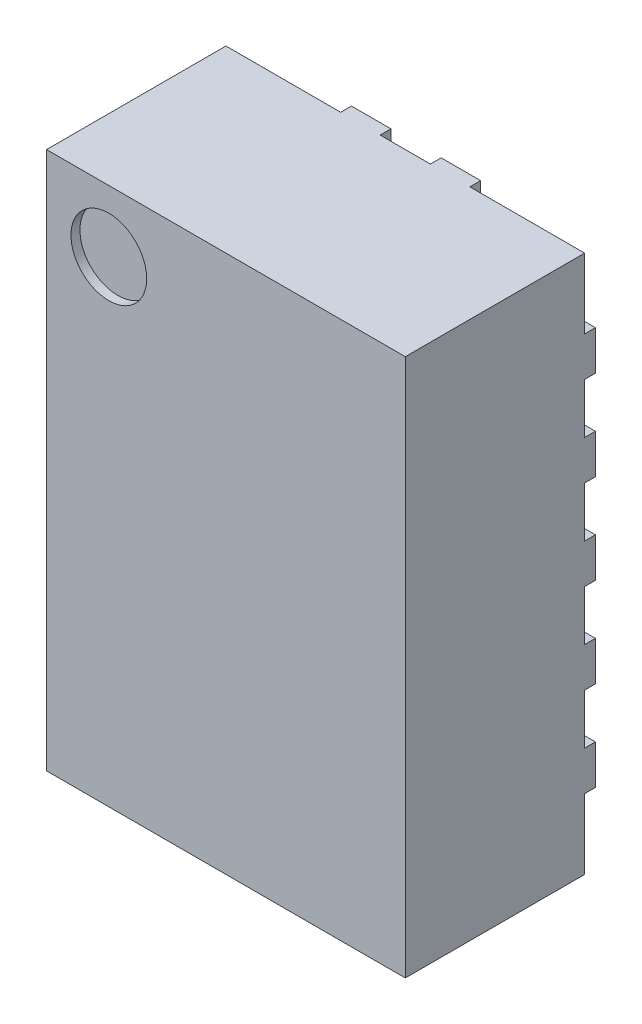
from build123d import *

# Parameters (mm, degrees)
BOSS_EXTRUDE1_START = 0.06
SKETCH1_W           = 2
SKETCH1_H           = 3
BOSS_EXTRUDE1_DEPTH = 1
BOSS_EXTRUDE2_DEPTH = 0.06
CUT_EXTRUDE2_DEPTH  = 0.06
SKETCH2_R           = 0.211135496
CUT_EXTRUDE3_DEPTH  = 0.05


with BuildPart() as part:
    # Sketch1 → Boss-Extrude1 (new body)
    with BuildSketch(Plane.XY.offset(BOSS_EXTRUDE1_START)):
        Rectangle(SKETCH1_W, SKETCH1_H)
    extrude(amount=BOSS_EXTRUDE1_DEPTH)

    # Sketch3 → Boss-Extrude2 (add)
    with BuildSketch(Plane(origin=(0, 0, 0.06), x_dir=(-1, 0, 0), z_dir=(0, 0, -1))):
        with BuildLine():
            Line((1, -0.11), (0.11, -0.11))
            ThreePointArc((0.11, -0.11), (0, 0), (0.11, 0.11))
            Line((0.11, 0.11), (1, 0.11))
            Line((1, 0.11), (1, -0.11))
        make_face()
        with BuildLine():
            Line((1, -0.61), (0.45, -0.61))
            ThreePointArc((0.45, -0.61), (0.34, -0.5), (0.45, -0.39))
            Line((0.45, -0.39), (1, -0.39))
            Line((1, -0.39), (1, -0.61))
        make_face()
        with BuildLine():
            Line((1, -1.11), (0.6, -1.11))
            ThreePointArc((0.6, -1.11), (0.49, -1), (0.6, -0.89))
            Line((0.6, -0.89), (1, -0.89))
            Line((1, -0.89), (1, -1.11))
        make_face()
        with BuildLine():
            Line((-1, 0.11), (-0.45, 0.11))
            ThreePointArc((-0.45, 0.11), (-0.34, 0), (-0.45, -0.11))
            Line((-0.45, -0.11), (-1, -0.11))
            Line((-1, -0.11), (-1, 0.11))
        make_face()
        with BuildLine():
            Line((-1, -0.61), (-1, -0.39))
            Line((-1, -0.39), (-0.45, -0.39))
            ThreePointArc((-0.45, -0.39), (-0.34, -0.5), (-0.45, -0.61))
            Line((-0.45, -0.61), (-1, -0.61))
        make_face()
        with BuildLine():
            Line((-1, -1.11), (-1, -0.89))
            Line((-1, -0.89), (-0.6, -0.89))
            ThreePointArc((-0.6, -0.89), (-0.49, -1), (-0.6, -1.11))
            Line((-0.6, -1.11), (-1, -1.11))
        make_face()
        with BuildLine():
            Line((-0.36, -1.5), (-0.36, -1.1))
            ThreePointArc((-0.36, -1.1), (-0.25, -0.99), (-0.14, -1.1))
            Line((-0.14, -1.1), (-0.14, -1.5))
            Line((-0.14, -1.5), (-0.36, -1.5))
        make_face()
        with BuildLine():
            Line((0.36, -1.5), (0.36, -1.1))
            ThreePointArc((0.36, -1.1), (0.25, -0.99), (0.14, -1.1))
            Line((0.14, -1.1), (0.14, -1.5))
            Line((0.14, -1.5), (0.36, -1.5))
        make_face()
    boss_extrude2 = extrude(amount=BOSS_EXTRUDE2_DEPTH)

    # Mirror1: Boss-Extrude2 across plane
    add(boss_extrude2.mirror(Plane.ZX))

    # Sketch4 → Cut-Extrude2 (cut)
    with BuildSketch(Plane(origin=(0, 0, 0), x_dir=(-1, 0, 0), z_dir=(0, 0, -1))):
        Polygon((0.672992218, 1.131770283), (0.453793128, 0.972393156), (0.453793128, 1.155108585), align=None)
    extrude(amount=-CUT_EXTRUDE2_DEPTH, mode=Mode.SUBTRACT)

    # Sketch2 → Cut-Extrude3 (cut)
    with BuildSketch(Plane.XY.offset(1.06)):
        with Locations((-0.652977304, 1.155108585)):
            Circle(SKETCH2_R)
    extrude(amount=-CUT_EXTRUDE3_DEPTH, mode=Mode.SUBTRACT)


solid = part.part
